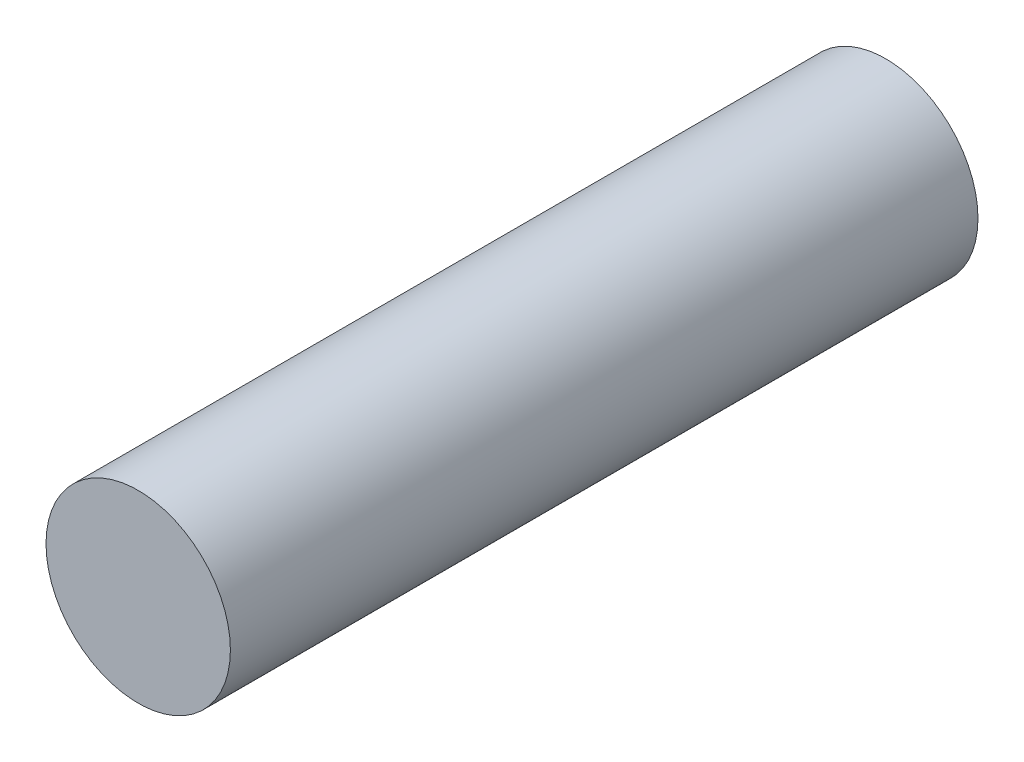
from build123d import *

# Parameters (mm, degrees)
SKETCH1_R          = 4.699
BASE_EXTRUDE_DEPTH = 38.1
SCALE1_SCALE       = 0.8


with BuildPart() as part:
    # Sketch1 → Base-Extrude (new body)
    with BuildSketch(Plane.XY):
        Circle(SKETCH1_R)
    extrude(amount=BASE_EXTRUDE_DEPTH)


with BuildPart() as part_1:
    # Scale1: scaled about (0, 0, 19.05)
    add(part.part.scale(SCALE1_SCALE).moved(Location((0, 0, 3.81))))


solid = part_1.part
